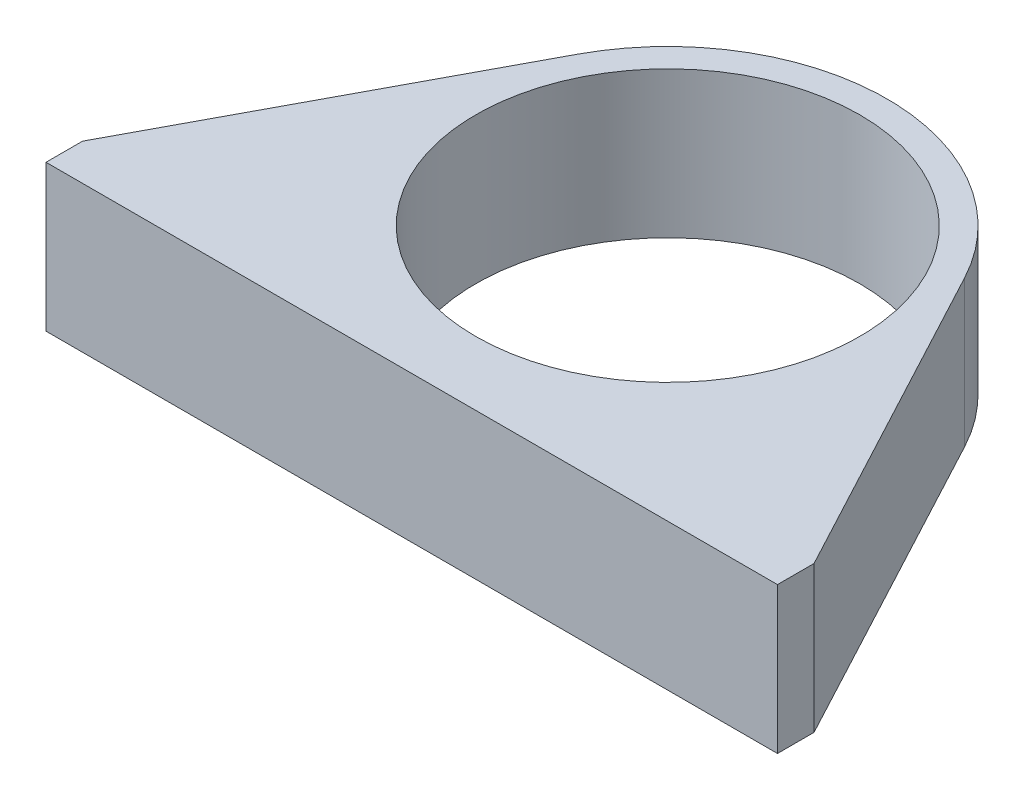
from build123d import *

# Parameters (mm, degrees)
SKETCH1_R           = 30
BOSS_EXTRUDE1_DEPTH = 20
SKETCH2_R           = 26.25
CUT_EXTRUDE1_DEPTH  = 20


with BuildPart() as part:
    # Sketch1 → Boss-Extrude1 (new body)
    with BuildSketch(Plane(origin=(0, 0, 0), x_dir=(1, 0, 0), z_dir=(0, 1, 0))):
        Circle(SKETCH1_R)
        with BuildLine():
            Line((-26.470588235, 14.117647059), (-50, -30))
            Line((-50, -30), (-50, -35))
            Line((-50, -35), (50, -35))
            Line((50, -35), (50, -30))
            Line((50, -30), (26.470588235, 14.117647059))
            ThreePointArc((26.470588235, 14.117647059), (29.104275004, 7.276068751), (30, 0))
            ThreePointArc((30, 0), (-7.276068751, -29.104275004), (-26.470588235, 14.117647059))
        make_face()
    extrude(amount=BOSS_EXTRUDE1_DEPTH)

    # Sketch2 → Cut-Extrude1 (cut)
    with BuildSketch(Plane(origin=(0, 0, 0), x_dir=(1, 0, 0), z_dir=(0, 1, 0))):
        Circle(SKETCH2_R)
    extrude(amount=CUT_EXTRUDE1_DEPTH, mode=Mode.SUBTRACT)


solid = part.part
